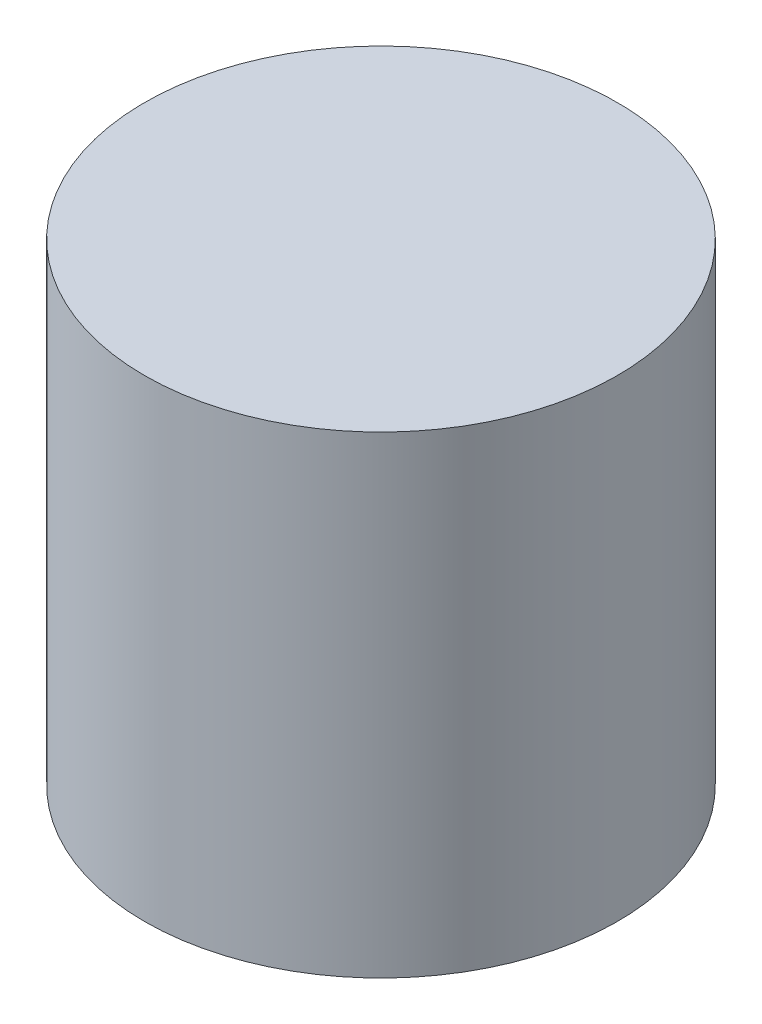
from build123d import *

# Parameters (mm, degrees)
SKETCH1_R           = 7.5
BOSS_EXTRUDE1_DEPTH = 15


with BuildPart() as part:
    # Sketch1 → Boss-Extrude1 (new body)
    with BuildSketch(Plane(origin=(0, 0, 0), x_dir=(1, 0, 0), z_dir=(0, 1, 0))):
        Circle(SKETCH1_R)
    extrude(amount=BOSS_EXTRUDE1_DEPTH)


solid = part.part
